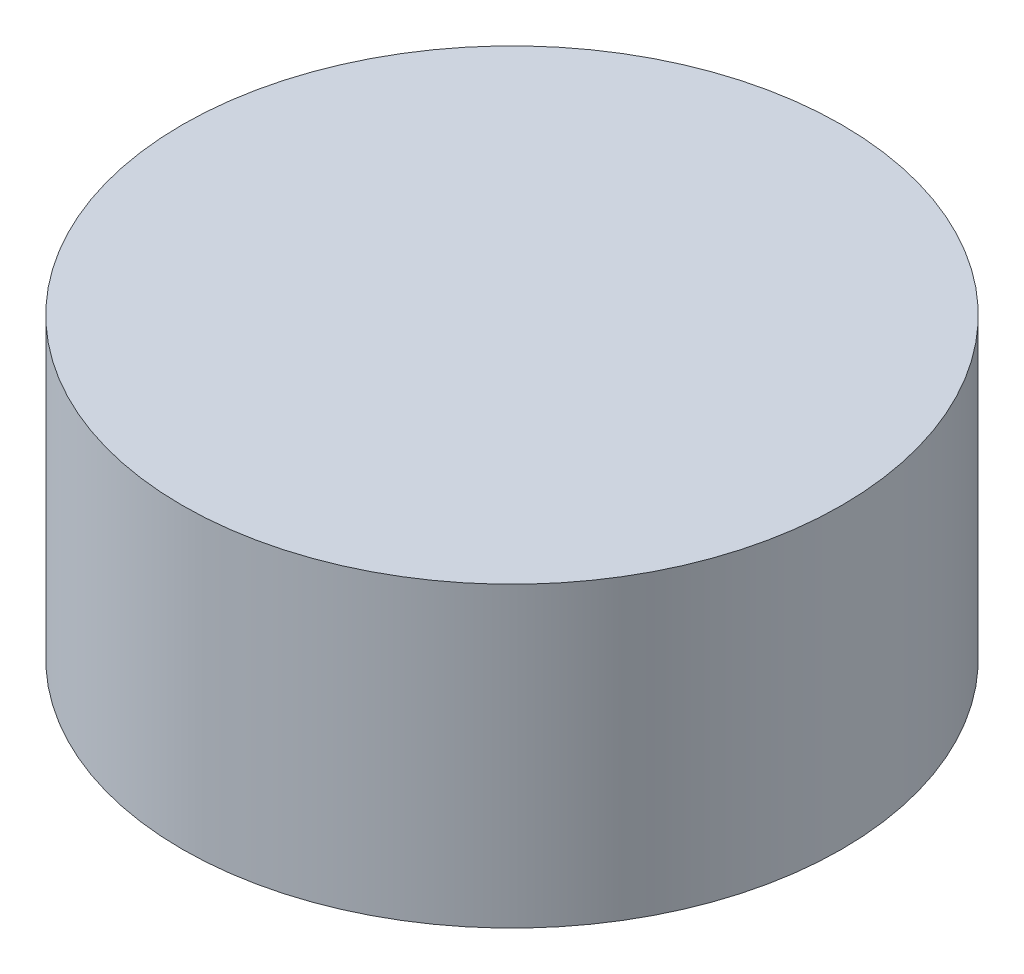
from build123d import *

# Parameters (mm, degrees)
ESBO_O1_R                = 7.75
RESSALTO_EXTRUS_O1_DEPTH = 7


with BuildPart() as part:
    # Esboço1 → Ressalto-extrusão1 (new body)
    with BuildSketch(Plane(origin=(0, 0, 0), x_dir=(1, 0, 0), z_dir=(0, 1, 0))):
        Circle(ESBO_O1_R)
    extrude(amount=RESSALTO_EXTRUS_O1_DEPTH)


solid = part.part
